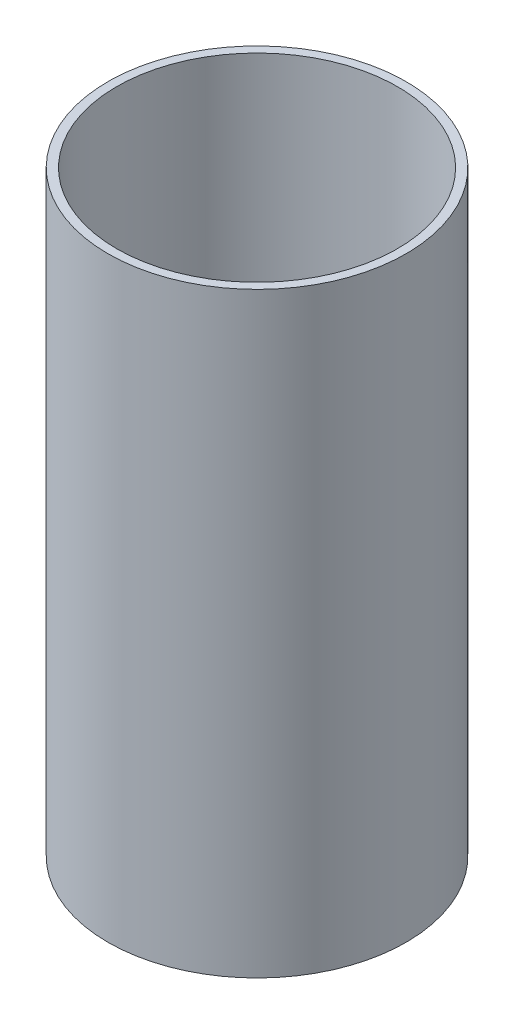
from build123d import *

# Parameters (mm, degrees)
SKETCH1_R   = 6.35
SKETCH1_R_2 = 5.98076085


with BuildPart() as part:
    # Sweep1: sweep along a path in Sketch2
    with BuildLine(Plane(origin=(0, 0, 0), x_dir=(0, 0, -1), z_dir=(1, 0, 0))) as sweep1_path:
        Line((0, 0), (0, -25.4))
    # Sketch1 → Sweep1 (sweep)
    with BuildSketch(Plane(origin=(0, 0, 0), x_dir=(1, 0, 0), z_dir=(0, 1, 0))):
        Circle(SKETCH1_R)
        Circle(SKETCH1_R_2, mode=Mode.SUBTRACT)
    sweep(path=sweep1_path.line)


solid = part.part
